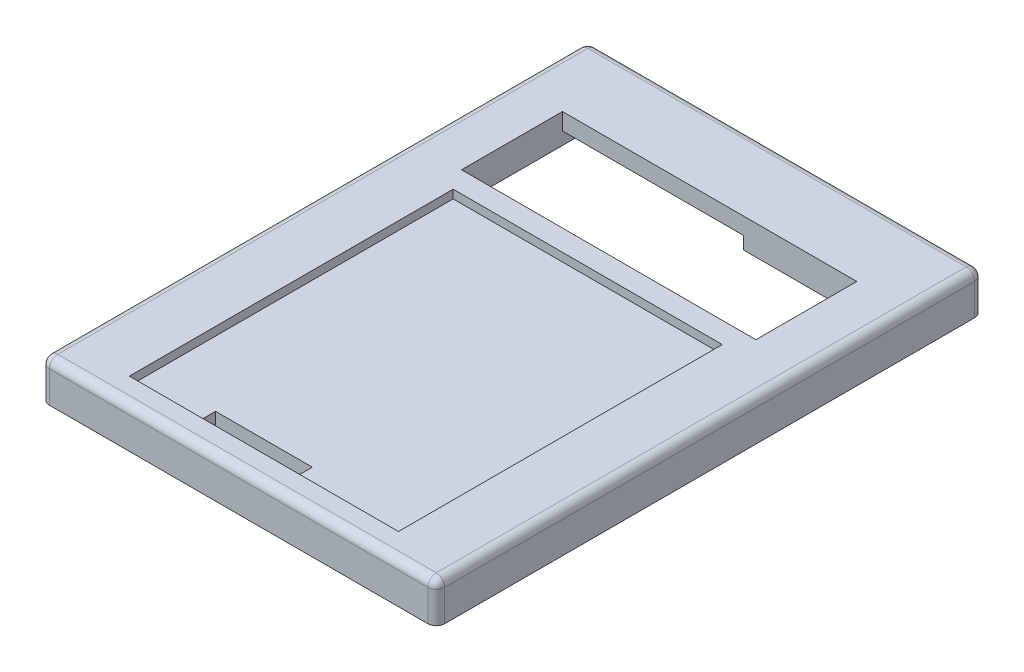
from build123d import *

# Parameters (mm, degrees)
SKETCH1_W           = 94
SKETCH1_H           = 130
BOSS_EXTRUDE1_DEPTH = 9.5
SKETCH2_W           = 90.5
SKETCH2_H           = 126.5
CUT_EXTRUDE1_DEPTH  = 2.5
SKETCH3_W           = 70
SKETCH3_H           = 24
CUT_EXTRUDE2_DEPTH  = 8
SKETCH4_W           = 64
SKETCH4_H           = 77
CUT_EXTRUDE3_DEPTH  = 2
SKETCH5_W           = 23
SKETCH5_H           = 3.5
CUT_EXTRUDE4_DEPTH  = 8.5
SKETCH6_W           = 6
SKETCH6_H           = 18
CUT_EXTRUDE5_DEPTH  = 3.5
SKETCH7_W           = 43
SKETCH7_H           = 7.5
CUT_EXTRUDE6_DEPTH  = 3
FILLET1_R           = 2


with BuildPart() as part:
    # Sketch1 → Boss-Extrude1 (new body)
    with BuildSketch(Plane(origin=(0, 7, 0), x_dir=(1, 0, 0), z_dir=(0, 1, 0))):
        with Locations((47, 65)):
            Rectangle(SKETCH1_W, SKETCH1_H)
    extrude(amount=-BOSS_EXTRUDE1_DEPTH)

    # Sketch2 → Cut-Extrude1 (cut)
    with BuildSketch(Plane.XZ.offset(2.5)):
        with Locations((47, -65)):
            Rectangle(SKETCH2_W, SKETCH2_H)
    extrude(amount=-CUT_EXTRUDE1_DEPTH, mode=Mode.SUBTRACT)

    # Sketch3 → Cut-Extrude2 (cut, through all)
    with BuildSketch(Plane.XZ):
        with Locations((47, -100)):
            Rectangle(SKETCH3_W, SKETCH3_H)
    extrude(amount=-CUT_EXTRUDE2_DEPTH, mode=Mode.SUBTRACT)

    # Sketch4 → Cut-Extrude3 (cut)
    with BuildSketch(Plane(origin=(0, 7, 0), x_dir=(-1, 0, 0), z_dir=(0, 1, 0))):
        with Locations((-47, -44.5)):
            Rectangle(SKETCH4_W, SKETCH4_H)
    extrude(amount=-CUT_EXTRUDE3_DEPTH, mode=Mode.SUBTRACT)

    # Sketch5 → Cut-Extrude4 (cut, through all)
    with BuildSketch(Plane(origin=(0, 5, 0), x_dir=(-1, 0, 0), z_dir=(0, 1, 0))):
        with Locations((-42, -9.25)):
            Rectangle(SKETCH5_W, SKETCH5_H)
    extrude(amount=-CUT_EXTRUDE4_DEPTH, mode=Mode.SUBTRACT)

    # Sketch6 → Cut-Extrude5 (cut)
    with BuildSketch(Plane.XZ):
        with Locations((85, -100)):
            Rectangle(SKETCH6_W, SKETCH6_H)
    extrude(amount=-CUT_EXTRUDE5_DEPTH, mode=Mode.SUBTRACT)

    # Sketch7 → Cut-Extrude6 (cut)
    with BuildSketch(Plane.XZ):
        with Locations((33.5, -115.75)):
            Rectangle(SKETCH7_W, SKETCH7_H)
    extrude(amount=-CUT_EXTRUDE6_DEPTH, mode=Mode.SUBTRACT)

    # Fillet1
    fillet1_edges = [part.edges().sort_by_distance(p)[0] for p in [
        (94, 7, -65),
        (47, 7, 0),
        (0, 7, -65),
        (47, 7, -130),
        (94, 2.25, -130),
        (94, 2.25, 0),
        (0, 2.25, 0),
        (0, 2.25, -130),
    ]]
    fillet(fillet1_edges, radius=FILLET1_R)


solid = part.part
